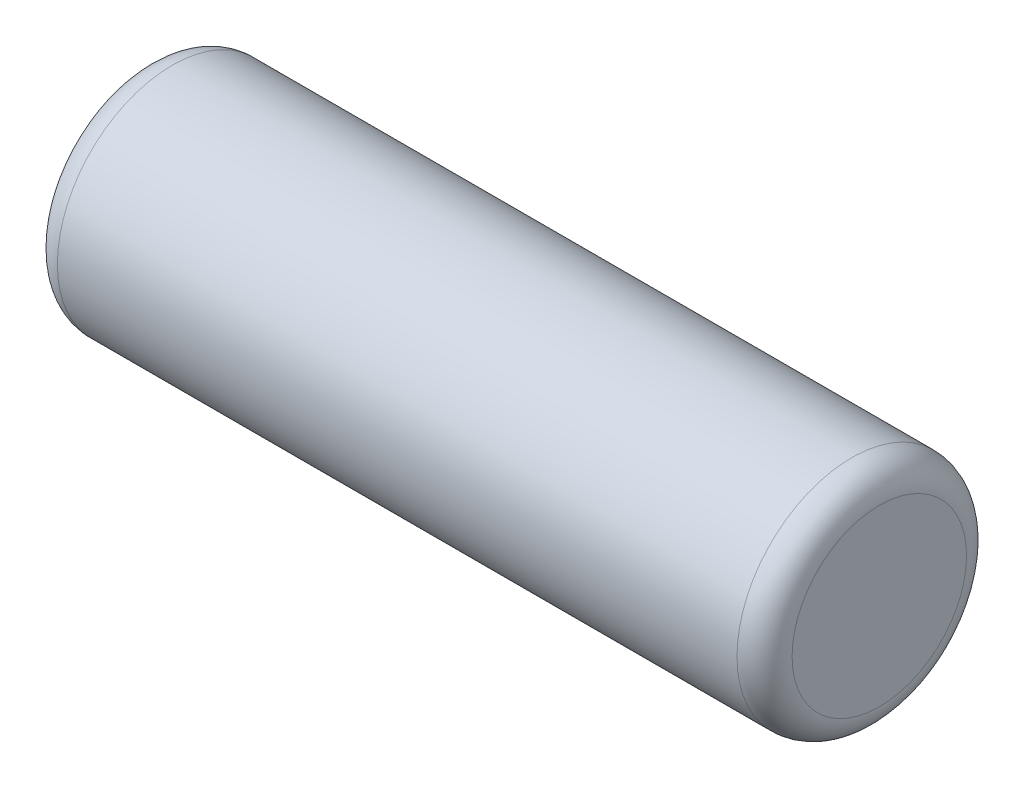
from build123d import *

# Parameters (mm, degrees)
ESQUISSE1_W = 8
ESQUISSE1_H = 1.25
CONG_1_R    = 0.3


with BuildPart() as part:
    # Esquisse1 → Base-Révolution (revolve)
    with BuildSketch(Plane.XY):
        with Locations((0, 0.625)):
            Rectangle(ESQUISSE1_W, ESQUISSE1_H)
    revolve(axis=Axis((-17, 0, 0), (1, 0, 0)))

    # Congé1
    cong_1_edges = [part.edges().sort_by_distance(p)[0] for p in [
        (4, -1.25, 0),
        (-4, -1.25, 0),
    ]]
    fillet(cong_1_edges, radius=CONG_1_R)


solid = part.part
